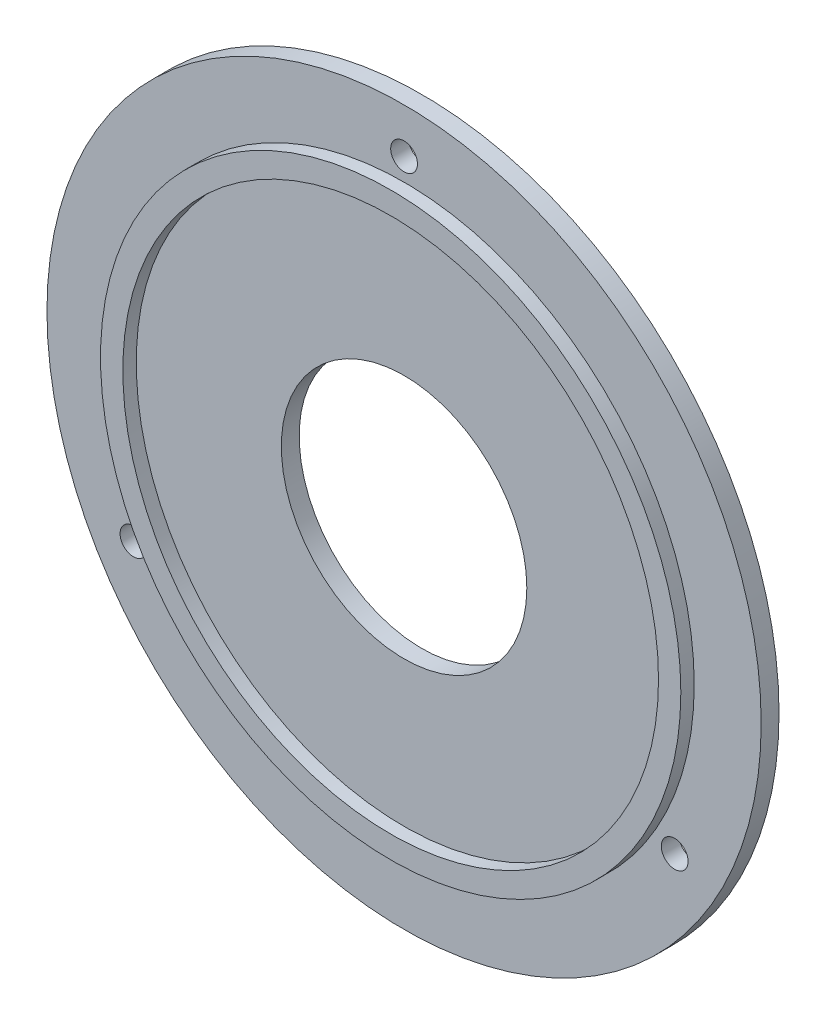
from build123d import *

# Parameters (mm, degrees)
SKETCH1_R           = 80
BOSS_EXTRUDE1_DEPTH = 4
SKETCH2_R           = 65
SKETCH2_R_2         = 60
BOSS_EXTRUDE2_DEPTH = 3
SKETCH3_R           = 3
CUT_EXTRUDE2_DEPTH  = 8
SKETCH5_R           = 27.5
CUT_EXTRUDE4_DEPTH  = 8


with BuildPart() as part:
    # Sketch1 → Boss-Extrude1 (new body)
    with BuildSketch(Plane.XY):
        Circle(SKETCH1_R)
    extrude(amount=BOSS_EXTRUDE1_DEPTH)

    # Sketch2 → Boss-Extrude2 (add)
    with BuildSketch(Plane.XY.offset(4)):
        Circle(SKETCH2_R)
        Circle(SKETCH2_R_2, mode=Mode.SUBTRACT)
    extrude(amount=BOSS_EXTRUDE2_DEPTH)

    # Sketch3 → Cut-Extrude2 (cut, through all)
    with BuildSketch(Plane(origin=(0, 0, 0), x_dir=(-1, 0, 0), z_dir=(0, 0, -1))):
        with Locations((0, 70)):
            Circle(SKETCH3_R)
        with Locations((60.621778265, -35)):
            Circle(SKETCH3_R)
        with Locations((-60.621778265, -35)):
            Circle(SKETCH3_R)
    extrude(amount=-CUT_EXTRUDE2_DEPTH, mode=Mode.SUBTRACT)

    # Sketch5 → Cut-Extrude4 (cut, through all)
    with BuildSketch(Plane.XY):
        Circle(SKETCH5_R)
    extrude(amount=CUT_EXTRUDE4_DEPTH, mode=Mode.SUBTRACT)


solid = part.part
